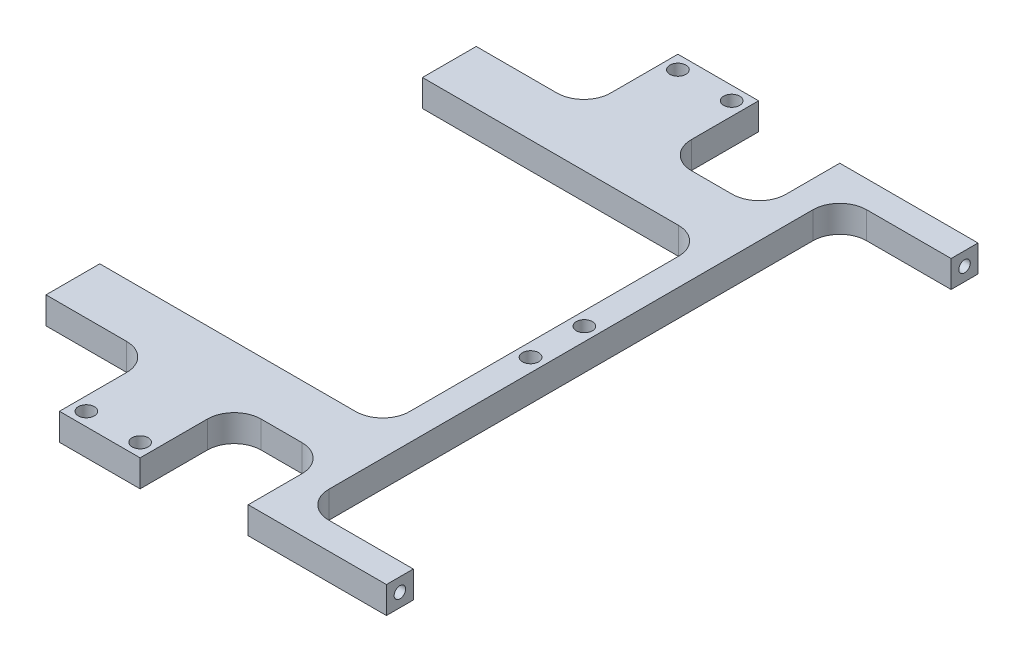
from build123d import *

# Parameters (mm, degrees)
SKETCH1_W                  = 99.441
SKETCH1_H                  = 139.7
EXTRUDE1_DEPTH             = 6.35
SKETCH2_W                  = 66.802
SKETCH2_H                  = 19.05
SKETCH2_W_2                = 26.289
SKETCH2_H_2                = 127
SKETCH2_H_3                = 76.2
CUT_EXTRUDE1_DEPTH         = 6.35
FILLET1_R                  = 6.35
TAP_DRILL_FOR_6_TAP1_D     = 2.7051
TAP_DRILL_FOR_6_TAP1_DEPTH = 12.7
TAP_DRILL_FOR_6_TAP1_TIP   = 0.81269403
TAP_DRILL_FOR_6_TAP2_D     = 2.7051
TAP_DRILL_FOR_6_TAP2_DEPTH = 12.7
TAP_DRILL_FOR_6_TAP2_TIP   = 0.81269403
F_6_CLEARANCE_HOLE1_D      = 3.7973
F_6_CLEARANCE_HOLE1_DEPTH  = 12.7
F_6_CLEARANCE_HOLE1_TIP    = 1.140824014
SKETCH6_W                  = 19.05
SKETCH6_H                  = 22.225
EXTRUDE2_DEPTH             = 6.35
FILLET2_R                  = 6.35
F_6_CLEARANCE_HOLE2_D      = 3.7973
F_6_CLEARANCE_HOLE2_DEPTH  = 12.7
F_6_CLEARANCE_HOLE2_TIP    = 1.140824014


with BuildPart() as part:
    # Sketch1 → Extrude1 (new body)
    with BuildSketch(Plane(origin=(0, 0, 0), x_dir=(1, 0, 0), z_dir=(0, 1, 0))):
        Rectangle(SKETCH1_W, SKETCH1_H)
    extrude(amount=EXTRUDE1_DEPTH)

    # Sketch2 → Cut-Extrude1 (cut)
    with BuildSketch(Plane(origin=(0, 6.35, 0), x_dir=(-1, 0, 0), z_dir=(0, 1, 0))):
        with Locations((16.3195, -60.325)):
            Rectangle(SKETCH2_W, SKETCH2_H)
        with Locations((16.3195, 60.325)):
            Rectangle(SKETCH2_W, SKETCH2_H)
        with Locations((-36.576, 0)):
            Rectangle(SKETCH2_W_2, SKETCH2_H_2)
        with Locations((16.3195, 0)):
            Rectangle(SKETCH2_W, SKETCH2_H_3)
    extrude(amount=-CUT_EXTRUDE1_DEPTH, mode=Mode.SUBTRACT)

    # Fillet1
    fillet1_edges = [part.edges().sort_by_distance(p)[0] for p in [
        (17.0815, 3.175, -50.8),
        (17.0815, 3.175, 50.8),
        (23.4315, 3.175, 63.5),
        (23.4315, 3.175, -63.5),
        (17.0815, 3.175, -38.1),
        (17.0815, 3.175, 38.1),
    ]]
    fillet(fillet1_edges, radius=FILLET1_R)

    # Tap Drill for #6 Tap1
    with Locations(Plane(origin=(-49.7205, 3.175, -44.45), x_dir=(0, 0, -1), z_dir=(-1, 0, 0))):
        with Locations((0, 0), (-88.9, 0)):
            Hole(TAP_DRILL_FOR_6_TAP1_D / 2, depth=TAP_DRILL_FOR_6_TAP1_DEPTH)
            with Locations((0, 0, -(TAP_DRILL_FOR_6_TAP1_DEPTH + TAP_DRILL_FOR_6_TAP1_TIP / 2))):  # 118° drill point
                Cone(0, TAP_DRILL_FOR_6_TAP1_D / 2, TAP_DRILL_FOR_6_TAP1_TIP, mode=Mode.SUBTRACT)

    # Tap Drill for #6 Tap2
    with Locations(Plane(origin=(49.7205, 3.175, -66.675), x_dir=(0, 0, 1), z_dir=(1, 0, 0))):
        with Locations((0, 0), (133.35, 0)):
            Hole(TAP_DRILL_FOR_6_TAP2_D / 2, depth=TAP_DRILL_FOR_6_TAP2_DEPTH)
            with Locations((0, 0, -(TAP_DRILL_FOR_6_TAP2_DEPTH + TAP_DRILL_FOR_6_TAP2_TIP / 2))):  # 118° drill point
                Cone(0, TAP_DRILL_FOR_6_TAP2_D / 2, TAP_DRILL_FOR_6_TAP2_TIP, mode=Mode.SUBTRACT)

    # #6 Clearance Hole1
    with Locations(Plane(origin=(20.2565, 0, 6.35), x_dir=(0, 0, -1), z_dir=(0, -1, 0))):
        with Locations((0, 0), (12.7, 0)):
            Hole(F_6_CLEARANCE_HOLE1_D / 2, depth=F_6_CLEARANCE_HOLE1_DEPTH)
            with Locations((0, 0, -(F_6_CLEARANCE_HOLE1_DEPTH + F_6_CLEARANCE_HOLE1_TIP / 2))):  # 118° drill point
                Cone(0, F_6_CLEARANCE_HOLE1_D / 2, F_6_CLEARANCE_HOLE1_TIP, mode=Mode.SUBTRACT)

    # Sketch6 → Extrude2 (add)
    with BuildSketch(Plane.XZ):
        with Locations((-14.7955, 61.9125)):
            Rectangle(SKETCH6_W, SKETCH6_H)
        with Locations((-14.7955, -61.9125)):
            Rectangle(SKETCH6_W, SKETCH6_H)
    extrude(amount=-EXTRUDE2_DEPTH)

    # Fillet2
    fillet2_edges = [part.edges().sort_by_distance(p)[0] for p in [
        (-5.2705, 3.175, 50.8),
        (-24.3205, 3.175, 50.8),
        (-5.2705, 3.175, -50.8),
        (-24.3205, 3.175, -50.8),
    ]]
    fillet(fillet2_edges, radius=FILLET2_R)

    # #6 Clearance Hole2
    with Locations(Plane(origin=(-8.4455, 0, 69.85), x_dir=(0, 0, -1), z_dir=(0, -1, 0))):
        with Locations((0, 0), (139.7, -12.7), (0, -12.7), (139.7, 0)):
            Hole(F_6_CLEARANCE_HOLE2_D / 2, depth=F_6_CLEARANCE_HOLE2_DEPTH)
            with Locations((0, 0, -(F_6_CLEARANCE_HOLE2_DEPTH + F_6_CLEARANCE_HOLE2_TIP / 2))):  # 118° drill point
                Cone(0, F_6_CLEARANCE_HOLE2_D / 2, F_6_CLEARANCE_HOLE2_TIP, mode=Mode.SUBTRACT)


solid = part.part
